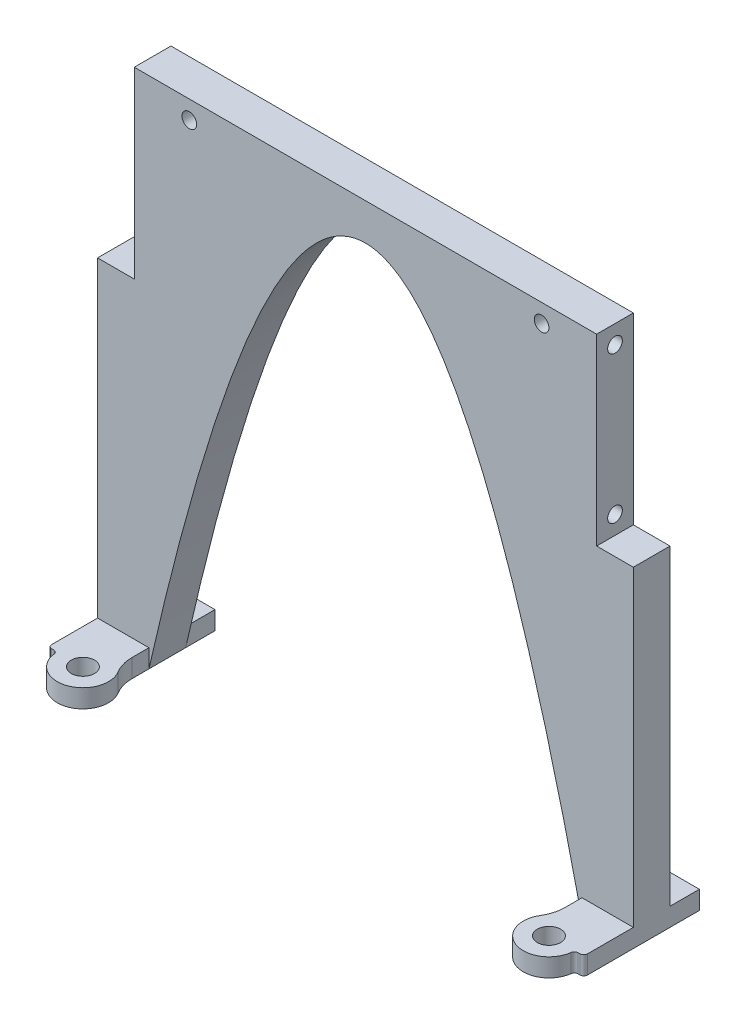
from build123d import *

# Parameters (mm, degrees)
SKETCH1_W           = 146
SKETCH1_H           = 140
BOSS_EXTRUDE1_DEPTH = 10
CUT_EXTRUDE1_DEPTH  = 10
SKETCH9_R           = 2
CUT_EXTRUDE4_DEPTH  = 20
SKETCH10_W          = 10
SKETCH10_H          = 10
CUT_EXTRUDE5_DEPTH  = 50
SKETCH12_R          = 3.175
BOSS_EXTRUDE2_DEPTH = 5
SKETCH14_W          = 14
SKETCH14_H          = 8
BOSS_EXTRUDE3_DEPTH = 5
SKETCH15_R          = 2
CUT_EXTRUDE6_DEPTH  = 20


with BuildPart() as part:
    # Sketch1 → Boss-Extrude1 (new body)
    with BuildSketch(Plane.XY):
        with Locations((73, 70)):
            Rectangle(SKETCH1_W, SKETCH1_H)
    extrude(amount=BOSS_EXTRUDE1_DEPTH)

    # Sketch4 → Cut-Extrude1 (cut)
    with BuildSketch(Plane.XY.offset(10)):
        with BuildLine():
            Line((14, 0), (132, 0))
            add(Edge.make_bspline(
                [(14, 0), (73, 260), (132, 0)],
                knots=[0, 0, 0, 1, 1, 1], degree=2))
        make_face()
    extrude(amount=-CUT_EXTRUDE1_DEPTH, mode=Mode.SUBTRACT)

    # Sketch9 → Cut-Extrude4 (cut)
    with BuildSketch(Plane.ZY):
        with Locations((5, 135)):
            Circle(SKETCH9_R)
        with Locations((5, 95)):
            Circle(SKETCH9_R)
    cut_extrude4 = extrude(amount=-CUT_EXTRUDE4_DEPTH, mode=Mode.SUBTRACT)

    # Sketch10 → Cut-Extrude5 (cut)
    with BuildSketch(Plane(origin=(0, 140, 0), x_dir=(1, 0, 0), z_dir=(0, 1, 0))):
        with Locations((5, -5)):
            Rectangle(SKETCH10_W, SKETCH10_H)
    cut_extrude5 = extrude(amount=-CUT_EXTRUDE5_DEPTH, mode=Mode.SUBTRACT)

    # Mirror3: Cut-Extrude4, Cut-Extrude5 across plane
    add(cut_extrude4.mirror(Plane.ZY.offset(-73)), mode=Mode.SUBTRACT)
    add(cut_extrude5.mirror(Plane.ZY.offset(-73)), mode=Mode.SUBTRACT)

    # Sketch12 → Boss-Extrude2 (add)
    with BuildSketch(Plane(origin=(0, 0, 0), x_dir=(1, 0, 0), z_dir=(0, 1, 0))):
        with BuildLine():
            Line((14, -10), (14, -14.625880325))
            ThreePointArc((14, -14.625880325), (14.374665781, -17.337511048), (15.470588235, -19.845950722))
            ThreePointArc((15.470588235, -19.845950722), (11.81635247, -30.105642379), (2.554902808, -24.375))
            ThreePointArc((2.554902808, -24.375), (2.224183895, -23.75), (1.562746067, -23.5))
            Line((1.562746067, -23.5), (1, -23.5))
            ThreePointArc((1, -23.5), (0.292893219, -23.207106781), (0, -22.5))
            Line((0, -22.5), (0, -10))
            Line((0, -10), (14, -10))
        make_face()
        with Locations(Location((9.5, -23.5, 0), (0, 0, 270))):
            Circle(SKETCH12_R, mode=Mode.SUBTRACT)
    boss_extrude2 = extrude(amount=BOSS_EXTRUDE2_DEPTH)

    # Mirror4: Boss-Extrude2 across plane
    add(boss_extrude2.mirror(Plane.ZY.offset(-73)))

    # Sketch14 → Boss-Extrude3 (add)
    with BuildSketch(Plane(origin=(0, 0, 0), x_dir=(1, 0, 0), z_dir=(0, 1, 0))):
        with Locations((7, 4)):
            Rectangle(SKETCH14_W, SKETCH14_H)
    boss_extrude3 = extrude(amount=BOSS_EXTRUDE3_DEPTH)

    # Mirror5: Boss-Extrude3 across plane
    add(boss_extrude3.mirror(Plane.ZY.offset(-73)))

    # Sketch15 → Cut-Extrude6 (cut)
    with BuildSketch(Plane.XY.offset(10)):
        with Locations((25, 135)):
            Circle(SKETCH15_R)
        with Locations((121, 135)):
            Circle(SKETCH15_R)
    extrude(amount=-CUT_EXTRUDE6_DEPTH, mode=Mode.SUBTRACT)


solid = part.part
